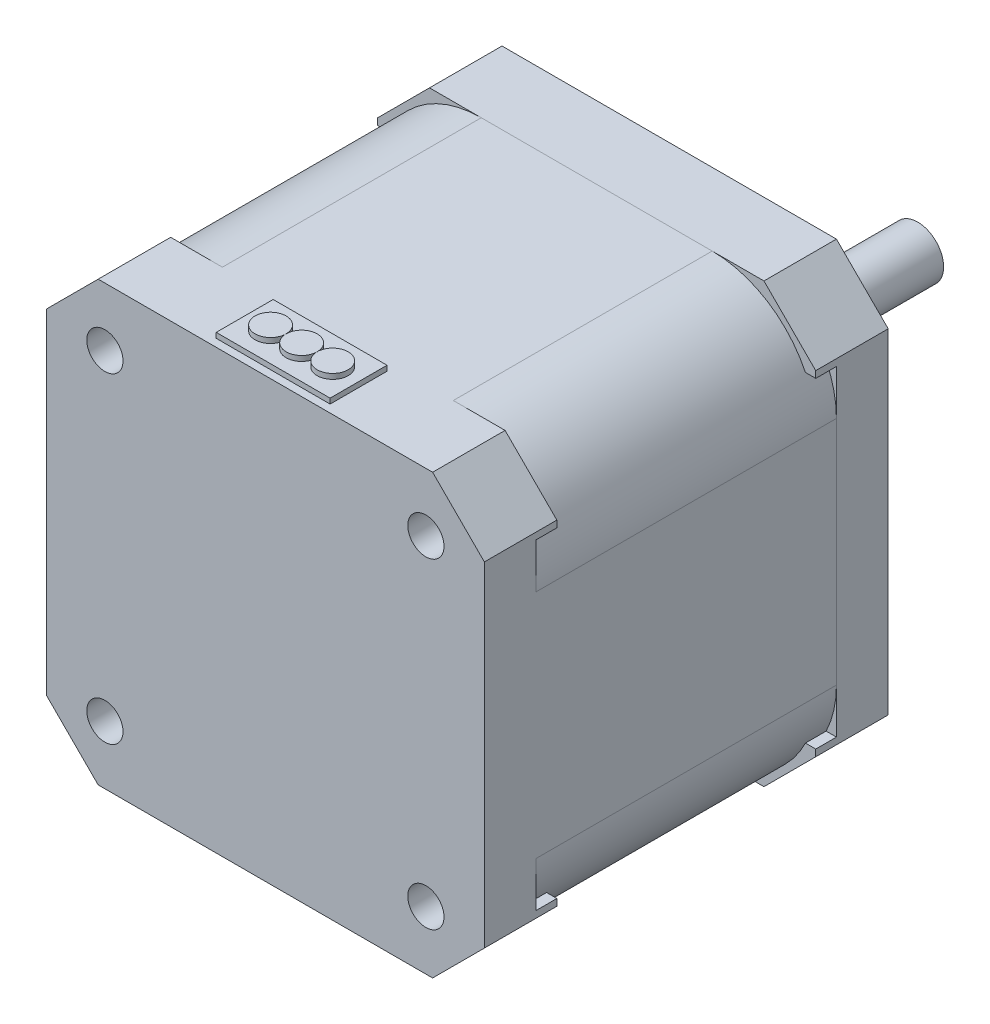
from build123d import *

# Parameters (mm, degrees)
ESQUISSE1_W             = 42.3
ESQUISSE1_H             = 42.3
ESQUISSE1_R             = 11
ESQUISSE1_R_2           = 1.75
ESQUISSE1_R_3           = 3.5
ESQUISSE1_R_4           = 2.5
BOSS_EXTRU_1_DEPTH      = 7
ESQUISSE1_3_R           = 11
ESQUISSE1_3_R_2         = 3.5
ESQUISSE1_3_R_3         = 2.5
BOSS_EXTRU_2_DEPTH      = 2
ESQUISSE1_5_R           = 2.5
BOSS_EXTRU_3_DEPTH      = 24
ENL_V_MAT_EXTRU_1_REACH = 55.034
ESQUISSE2_W             = 2
ESQUISSE2_H             = 31
ESQUISSE3_W             = 2
ESQUISSE3_H             = 31
BOSS_EXTRU_4_DEPTH      = 42.3
BOSS_EXTRU_5_DEPTH      = 42.3
ESQUISSE1_6_R           = 1.75
ENL_V_MAT_EXTRU_2_DEPTH = 39
CHANFREIN1_SIZE         = 5
CHANFREIN2_SIZE         = 5
CONG_1_R                = 10
ESQUISSE5_W             = 11
ESQUISSE5_H             = 5.5
BOSS_EXTRU_6_DEPTH      = 0.5
ESQUISSE5_3_R           = 1.5
BOSS_EXTRU_7_DEPTH      = 1
ESQUISSE5_5_R           = 1.5
BOSS_EXTRU_8_DEPTH      = 1
ESQUISSE5_6_R           = 1.5
BOSS_EXTRU_9_DEPTH      = 1


with BuildPart() as part:
    # Esquisse1 → Boss.-Extru.1 (new body)
    with BuildSketch(Plane.XY):
        Rectangle(ESQUISSE1_W, ESQUISSE1_H)
        Circle(ESQUISSE1_R, mode=Mode.SUBTRACT)
        with Locations((-15.5, -15.5)):
            Circle(ESQUISSE1_R_2, mode=Mode.SUBTRACT)
        with Locations((15.5, -15.5)):
            Circle(ESQUISSE1_R_2, mode=Mode.SUBTRACT)
        with Locations((15.5, 15.5)):
            Circle(ESQUISSE1_R_2, mode=Mode.SUBTRACT)
        with Locations((-15.5, 15.5)):
            Circle(ESQUISSE1_R_2, mode=Mode.SUBTRACT)
        Circle(ESQUISSE1_R)
        Circle(ESQUISSE1_R_3, mode=Mode.SUBTRACT)
        Circle(ESQUISSE1_R_3)
        Circle(ESQUISSE1_R_4, mode=Mode.SUBTRACT)
        Circle(ESQUISSE1_R_4)
    extrude(amount=BOSS_EXTRU_1_DEPTH)

    # Esquisse1_3 → Boss.-Extru.2 (add)
    with BuildSketch(Plane.XY):
        Circle(ESQUISSE1_3_R)
        Circle(ESQUISSE1_3_R_2, mode=Mode.SUBTRACT)
        Circle(ESQUISSE1_3_R_3)
    extrude(amount=-BOSS_EXTRU_2_DEPTH)

    # Esquisse1_5 → Boss.-Extru.3 (add)
    with BuildSketch(Plane.XY):
        Circle(ESQUISSE1_5_R)
    extrude(amount=-BOSS_EXTRU_3_DEPTH)

    # Esquisse2 → Enl_v. mat.-Extru.1 (cut, up to next)
    with BuildSketch(Plane.ZY.offset(21.15), mode=Mode.PRIVATE) as enl_v_mat_extru_1_sk1:
        with Locations((6, 0)):
            Rectangle(ESQUISSE2_W, ESQUISSE2_H)
    enl_v_mat_extru_1_tool1 = extrude(enl_v_mat_extru_1_sk1.sketch, amount=-ENL_V_MAT_EXTRU_1_REACH, mode=Mode.PRIVATE) & part.part
    add(enl_v_mat_extru_1_tool1.solids().sort_by_distance((-21.15, 0, 6))[0], mode=Mode.SUBTRACT)

    # Chanfrein1
    chanfrein1_edges = [part.edges().sort_by_distance(p)[0] for p in [
        (-21.15, 21.15, 3.5),
        (21.15, 21.15, 3.5),
        (21.15, -21.15, 3.5),
        (-21.15, -21.15, 3.5),
    ]]
    chamfer(chanfrein1_edges, length=CHANFREIN1_SIZE)


with BuildPart() as body_2:
    # Esquisse3 → Boss.-Extru.4 (new body)
    with BuildSketch(Plane.ZY.offset(21.15)):
        Polygon((32, 15.5), (32, 21.15), (7, 21.15), (7, 15.5), (7, -15.5), (7, -21.15), (32, -21.15), (32, -15.5), align=None)
        with Locations((33, 0)):
            Rectangle(ESQUISSE3_W, ESQUISSE3_H)
        with Locations((6, 0)):
            Rectangle(ESQUISSE3_W, ESQUISSE3_H)
    extrude(amount=-BOSS_EXTRU_4_DEPTH)


with BuildPart() as body_3:
    # Esquisse4 → Boss.-Extru.5 (new body)
    with BuildSketch(Plane.ZY.offset(21.15)):
        Polygon((32, 21.15), (39, 21.15), (39, -21.15), (32, -21.15), (32, -15.5), (34, -15.5), (34, 15.5), (32, 15.5), align=None)
    extrude(amount=-BOSS_EXTRU_5_DEPTH)


with BuildPart() as enl_v_mat_extru_2_tool:
    # Esquisse1_6 → Enl_v. mat.-Extru.2 (new body)
    with BuildSketch(Plane.XY):
        with Locations(Location((15.5, 15.5, 0), (0, 0, 180))):
            Circle(ESQUISSE1_6_R)
        with Locations(Location((-15.5, -15.5, 0), (0, 0, 180))):
            Circle(ESQUISSE1_6_R)
        with Locations(Location((15.5, -15.5, 0), (0, 0, 180))):
            Circle(ESQUISSE1_6_R)
        with Locations(Location((-15.5, 15.5, 0), (0, 0, 180))):
            Circle(ESQUISSE1_6_R)
    extrude(amount=ENL_V_MAT_EXTRU_2_DEPTH)


with BuildPart() as body_2_1:
    add(body_2.part)

    # Enl_v. mat.-Extru.2: cut by enl_v_mat_extru_2_tool
    add(enl_v_mat_extru_2_tool.part, mode=Mode.SUBTRACT)

    # Cong_1
    cong_1_edges = [body_2_1.edges().sort_by_distance(p)[0] for p in [
        (21.15, 21.15, 19.5),
        (-21.15, 21.15, 19.5),
        (21.15, -21.15, 19.5),
        (-21.15, -21.15, 19.5),
    ]]
    fillet(cong_1_edges, radius=CONG_1_R)



with BuildPart() as body_3_1:
    add(body_3.part)

    # Enl_v. mat.-Extru.2: cut by enl_v_mat_extru_2_tool
    add(enl_v_mat_extru_2_tool.part, mode=Mode.SUBTRACT)

    # Chanfrein2
    chanfrein2_edges = [body_3_1.edges().sort_by_distance(p)[0] for p in [
        (21.15, -21.15, 35.5),
        (21.15, 21.15, 35.5),
        (-21.15, 21.15, 35.5),
        (-21.15, -21.15, 35.5),
    ]]
    chamfer(chanfrein2_edges, length=CHANFREIN2_SIZE)


with BuildPart() as body_2_2:
    add(body_2_1.part)

    add(body_3_1.part)  # Boss.-Extru.6 merges body 3
    # Esquisse5 → Boss.-Extru.6 (add)
    with BuildSketch(Plane(origin=(0, 21.15, 0), x_dir=(1, 0, 0), z_dir=(0, 1, 0))):
        with Locations((0, -35.5)):
            Rectangle(ESQUISSE5_W, ESQUISSE5_H)
    extrude(amount=BOSS_EXTRU_6_DEPTH)

    # Esquisse5_3 → Boss.-Extru.7 (add)
    with BuildSketch(Plane(origin=(0, 21.15, 0), x_dir=(1, 0, 0), z_dir=(0, 1, 0))):
        with Locations(Location((-3, -35.5, 0), (0, 0, 270))):
            Circle(ESQUISSE5_3_R)
    extrude(amount=BOSS_EXTRU_7_DEPTH)

    # Esquisse5_5 → Boss.-Extru.8 (add)
    with BuildSketch(Plane(origin=(0, 21.15, 0), x_dir=(1, 0, 0), z_dir=(0, 1, 0))):
        with Locations(Location((3, -35.5, 0), (0, 0, 270))):
            Circle(ESQUISSE5_5_R)
    extrude(amount=BOSS_EXTRU_8_DEPTH)


with BuildPart() as body_3_2:
    # Esquisse5_6 → Boss.-Extru.9 (new body)
    with BuildSketch(Plane(origin=(0, 21.15, 0), x_dir=(1, 0, 0), z_dir=(0, 1, 0))):
        with Locations(Location((0, -35.5, 0), (0, 0, 270))):
            Circle(ESQUISSE5_6_R)
    extrude(amount=BOSS_EXTRU_9_DEPTH)


solid = Compound([part.part, body_2_2.part, body_3_2.part])
